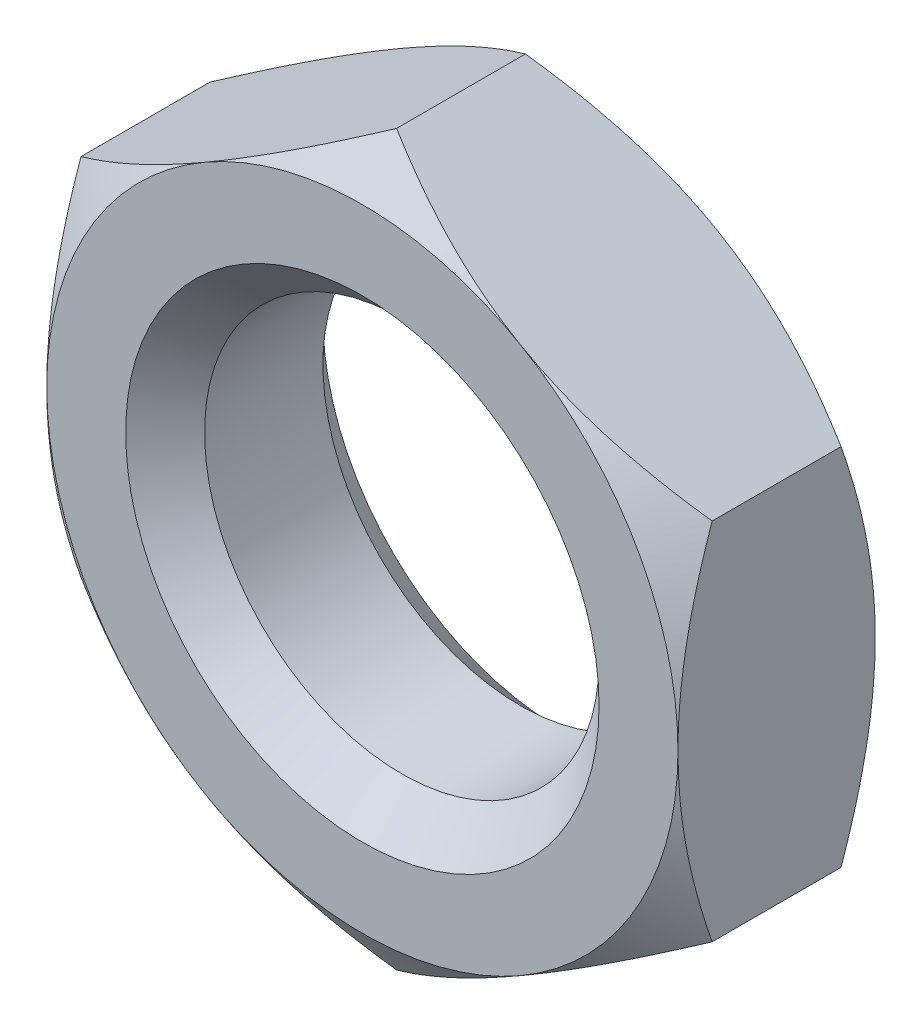
from build123d import *

# Parameters (mm, degrees)
SKETCH1_R           = 5
BOSS_EXTRUDE1_DEPTH = 2.5
SKETCH2_OUTSIDE_W   = 40.128
SKETCH2_OUTSIDE_H   = 42.604
SKETCH2_OUTSIDE_R   = 8
CUT_EXTRUDE1_DEPTH  = 6
CUT_EXTRUDE1_TAPER  = 55
CHAMFER1_SIZE       = 1


with BuildPart() as part:
    # Sketch1 → Boss-Extrude1 (new body, symmetric)
    with BuildSketch(Plane.XY):
        Polygon((-8, 4.618802154), (-8, -4.618802154), (0, -9.237604307), (8, -4.618802154), (8, 4.618802154), (0, 9.237604307), align=None)
        Circle(SKETCH1_R, mode=Mode.SUBTRACT)
    extrude(amount=BOSS_EXTRUDE1_DEPTH, both=True)

    # Sketch2 outside → Cut-Extrude1 (cut, through all)
    with BuildSketch(Plane.XY.offset(2.5)):
        Rectangle(SKETCH2_OUTSIDE_W, SKETCH2_OUTSIDE_H)
        Circle(SKETCH2_OUTSIDE_R, mode=Mode.SUBTRACT)
    cut_extrude1 = extrude(amount=-CUT_EXTRUDE1_DEPTH, taper=CUT_EXTRUDE1_TAPER, mode=Mode.SUBTRACT)

    # Mirror1: Cut-Extrude1 across plane
    add(cut_extrude1.mirror(Plane.XY), mode=Mode.SUBTRACT)

    # Chamfer1
    chamfer1_edges = [part.edges().sort_by_distance(p)[0] for p in [
        (-5, 0, -2.5),
        (-5, 0, 2.5),
    ]]
    chamfer(chamfer1_edges, length=CHAMFER1_SIZE)


solid = part.part
